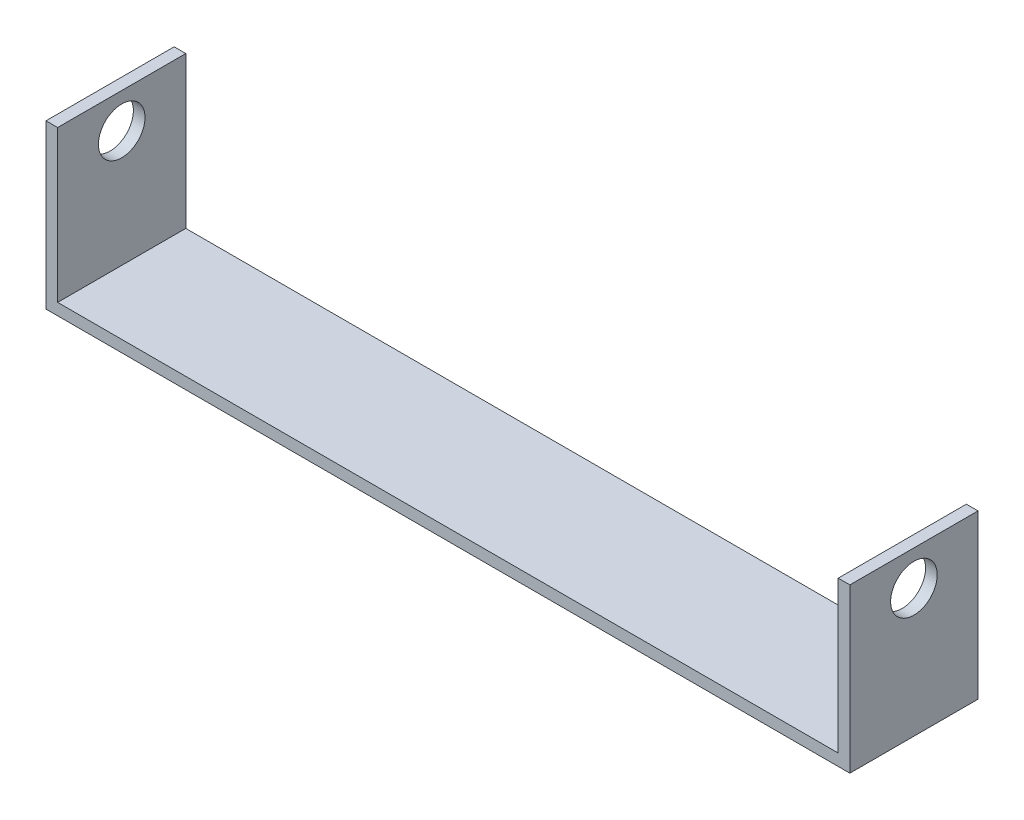
from build123d import *

# Parameters (mm, degrees)
BOSS_EXTRUDE1_DEPTH      = 27.5
BOSS_EXTRUDE1_DEPTH_BACK = 27.5
SKETCH2_R                = 10
CUT_EXTRUDE1_DEPTH       = 354.102322281


with BuildPart() as part:
    # Sketch1 → Boss-Extrude1 (new, two sides: drawn at the far end of the back side and taken through both)
    with BuildSketch(Plane.XY.offset(-BOSS_EXTRUDE1_DEPTH_BACK)):
        Polygon((-172.5, 0), (172.5, 0), (172.5, 70), (167.5, 70), (167.5, 5), (-167.5, 5), (-167.5, 70), (-172.5, 70), align=None)
    extrude(amount=BOSS_EXTRUDE1_DEPTH + BOSS_EXTRUDE1_DEPTH_BACK)

    # Sketch2 → Cut-Extrude1 (cut, through all)
    with BuildSketch(Plane(origin=(172.5, 0, 0), x_dir=(0, 0, -1), z_dir=(1, 0, 0))):
        with Locations((0, 55)):
            Circle(SKETCH2_R)
    extrude(amount=-CUT_EXTRUDE1_DEPTH, mode=Mode.SUBTRACT)


solid = part.part
